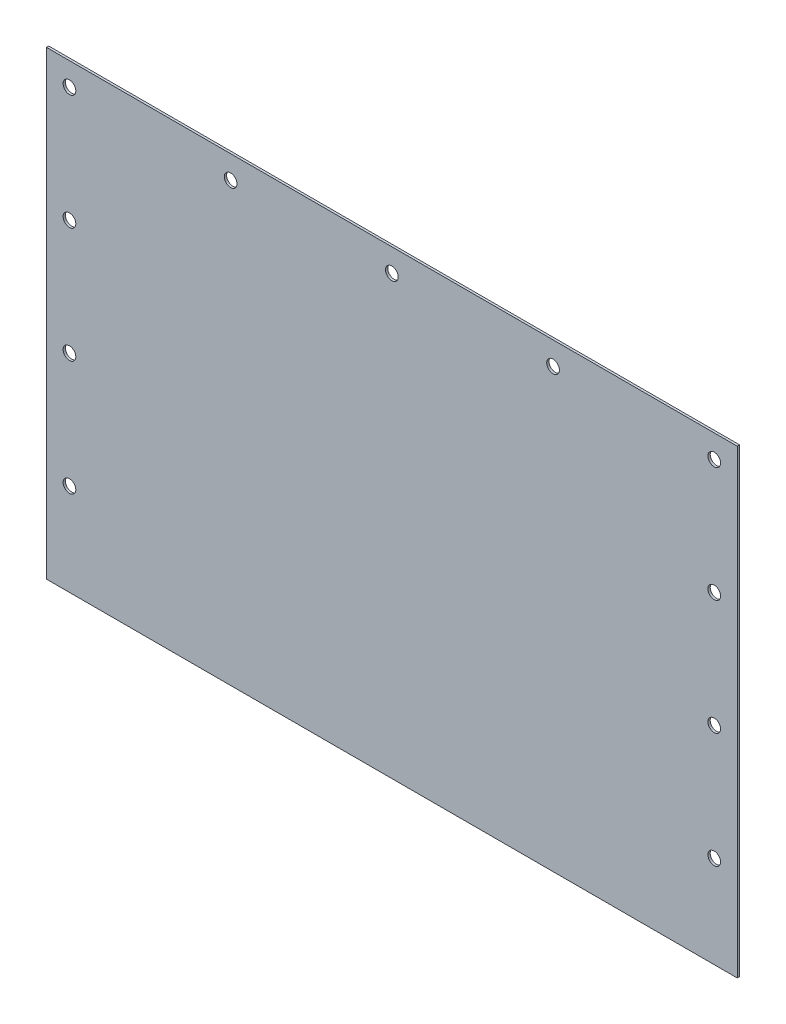
from build123d import *

# Parameters (mm, degrees)
SKETCH_1_W          = 300
SKETCH_1_H          = 220
EXTRUDE_1_DEPTH     = 1
HOLE_WIZARD_M5_1_D  = 5.5
SKETCH_4_W          = 300
SKETCH_4_H          = 20
CUT_EXTRUDE_1_DEPTH = 10


with BuildPart() as part:
    # 스케치1 → 보스-돌출1 (new body)
    with BuildSketch(Plane.XY):
        Rectangle(SKETCH_1_W, SKETCH_1_H)
    extrude(amount=EXTRUDE_1_DEPTH)

    # M5 여유 구멍1 (through all)
    with Locations(Plane(origin=(0, 0, 0), x_dir=(-1, 0, 0), z_dir=(0, 0, -1))):
        with Locations((-140, 100), (-70, 100), (70, 100), (0, 100), (140, 100), (140, 50), (140, -50), (140, 0), (140, -100), (-140, 50), (-140, -50), (-140, 0), (-140, -100), (-70, -100), (70, -100), (0, -100)):
            Hole(HOLE_WIZARD_M5_1_D / 2)

    # 스케치4 → 컷-돌출1 (cut)
    with BuildSketch(Plane.XY.offset(1)):
        with Locations((0, -100)):
            Rectangle(SKETCH_4_W, SKETCH_4_H)
    extrude(amount=-CUT_EXTRUDE_1_DEPTH, mode=Mode.SUBTRACT)


solid = part.part
